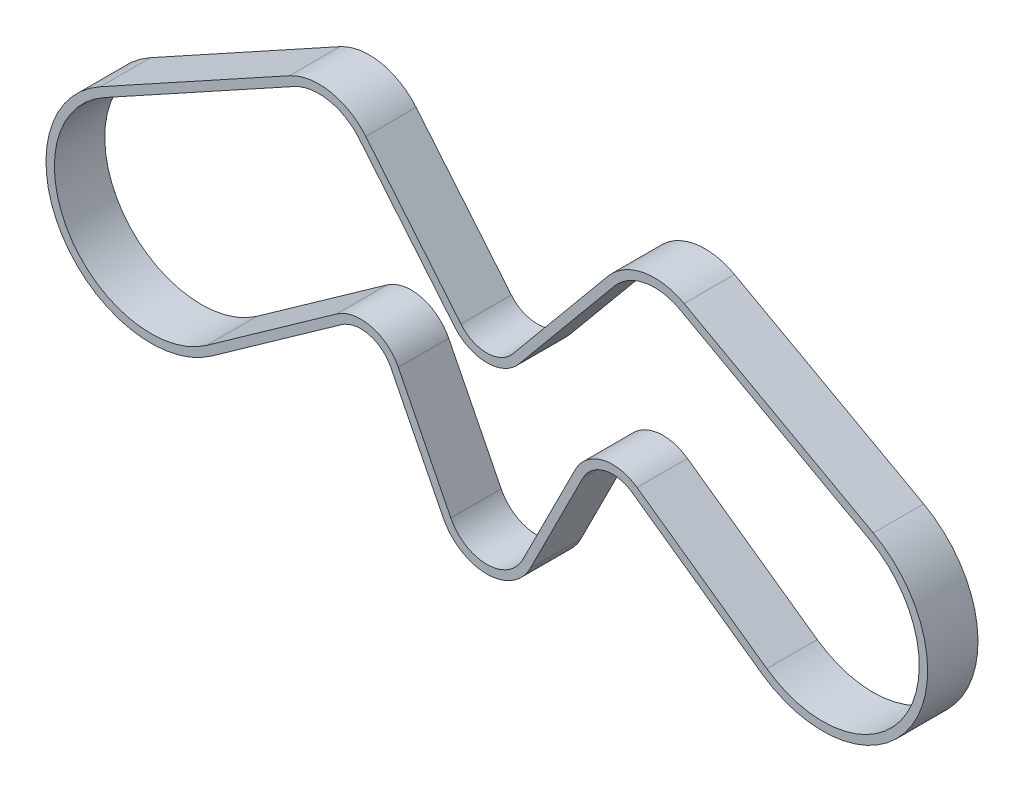
from build123d import *

# Parameters (mm, degrees)
SALIENTE_EXTRUIR1_DEPTH = 6


with BuildPart() as part:
    # Croquis1 → Saliente-Extruir1 (new body)
    with BuildSketch(Plane.XY):
        with BuildLine():
            ThreePointArc((7.230331915, -10.196680852), (-10.590936603, -6.639432345), (-6.027091132, 10.950989567))
            Line((-6.027091132, 10.950989567), (16.504287144, 23.351573949))
            ThreePointArc((16.504287144, 23.351573949), (21.353423494, 24.122551849), (25.581793113, 21.626671118))
            Line((25.581793113, 21.626671118), (36.920390006, 7.947353866))
            ThreePointArc((36.920390006, 7.947353866), (40, 6.5), (43.079609994, 7.947353866))
            Line((43.079609994, 7.947353866), (54.418206887, 21.626671118))
            ThreePointArc((54.418206887, 21.626671118), (58.646576506, 24.122551849), (63.495712856, 23.351573949))
            Line((63.495712856, 23.351573949), (86.027091132, 10.950989567))
            ThreePointArc((86.027091132, 10.950989567), (90.590936603, -6.639432345), (72.769668085, -10.196680852))
            Line((72.769668085, -10.196680852), (57.313706213, 0.762937873))
            ThreePointArc((57.313706213, 0.762937873), (54.034506659, 1.381729332), (51.427293643, -0.701175581))
            Line((51.427293643, -0.701175581), (45.180424217, -13.108295407))
            ThreePointArc((45.180424217, -13.108295407), (40, -16.3), (34.819575783, -13.108295407))
            Line((34.819575783, -13.108295407), (28.572706357, -0.701175581))
            ThreePointArc((28.572706357, -0.701175581), (25.965493341, 1.381729332), (22.686293787, 0.762937873))
            Line((22.686293787, 0.762937873), (7.230331915, -10.196680852))
        make_face()
        with BuildLine():
            Line((35.712752372, -12.658589302), (29.465882946, -0.251469477))
            ThreePointArc((29.465882946, -0.251469477), (26.206866677, 2.352161665), (22.107867234, 1.578672341))
            Line((22.107867234, 1.578672341), (6.651905362, -9.380946384))
            ThreePointArc((6.651905362, -9.380946384), (-9.743661675, -6.108277758), (-5.544923841, 10.074910401))
            Line((-5.544923841, 10.074910401), (16.986454434, 22.475494783))
            ThreePointArc((16.986454434, 22.475494783), (21.166744391, 23.140130905), (24.811890615, 20.988509585))
            Line((24.811890615, 20.988509585), (36.150487508, 7.309192332))
            ThreePointArc((36.150487508, 7.309192332), (40, 5.5), (43.849512492, 7.309192332))
            Line((43.849512492, 7.309192332), (55.188109385, 20.988509585))
            ThreePointArc((55.188109385, 20.988509585), (58.833255609, 23.140130905), (63.013545566, 22.475494783))
            Line((63.013545566, 22.475494783), (85.544923841, 10.074910401))
            ThreePointArc((85.544923841, 10.074910401), (89.743661675, -6.108277758), (73.348094638, -9.380946384))
            Line((73.348094638, -9.380946384), (57.892132766, 1.578672341))
            ThreePointArc((57.892132766, 1.578672341), (53.793133323, 2.352161665), (50.534117054, -0.251469477))
            Line((50.534117054, -0.251469477), (44.287247628, -12.658589302))
            ThreePointArc((44.287247628, -12.658589302), (40, -15.3), (35.712752372, -12.658589302))
        make_face(mode=Mode.SUBTRACT)
    extrude(amount=SALIENTE_EXTRUIR1_DEPTH)


solid = part.part
